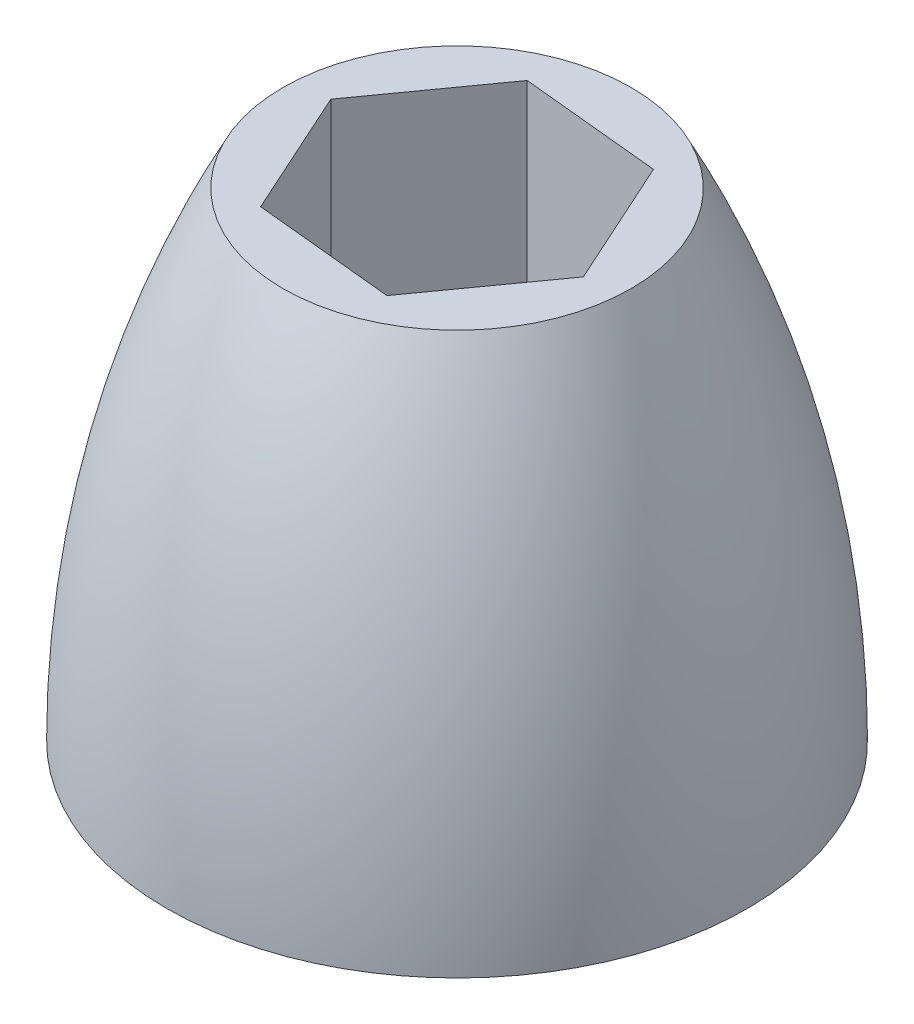
from build123d import *

# Parameters (mm, degrees)
SKETCH1_R               = 19.05
BOSS_EXTRUDE1_DEPTH     = 104.775
CUT_EXTRUDE1_DEPTH      = 104.775
SKETCH5_W               = 79.059329342
SKETCH5_H               = 52.3875
CUT_EXTRUDE2_DEPTH      = 32.7500001
CUT_EXTRUDE2_DEPTH_BACK = 32.7500001


with BuildPart() as part:
    # Sketch1 → Boss-Extrude1 (new body)
    with BuildSketch(Plane(origin=(0, 0, 0), x_dir=(1, 0, 0), z_dir=(0, 1, 0))):
        Circle(SKETCH1_R)
    extrude(amount=BOSS_EXTRUDE1_DEPTH)

    # Sketch2 → Cut-Extrude1 (cut)
    with BuildSketch(Plane.XZ):
        Polygon((-15.323636661, -1.510781079), (-6.353443536, -14.026049167), (8.970193125, -12.515268087), (15.323636661, 1.510781079), (6.353443536, 14.026049167), (-8.970193125, 12.515268087), align=None)
    extrude(amount=-CUT_EXTRUDE1_DEPTH, mode=Mode.SUBTRACT)

    # Sketch4 → Revolve1 (revolve)
    with BuildSketch(Plane.XY):
        with BuildLine():
            Line((-19.05, 104.775), (-19.05, 0))
            ThreePointArc((-19.05, 0), (-31.75, 52.3875), (-19.05, 104.775))
        make_face()
    revolve(axis=Axis((0, 0, 0), (0, 1, 0)))

    # Sketch5 → Cut-Extrude2 (cut, two sides)
    with BuildSketch(Plane.XY) as cut_extrude2_sk:
        with Locations((-0.139680794, 26.19375)):
            Rectangle(SKETCH5_W, SKETCH5_H)
    extrude(amount=CUT_EXTRUDE2_DEPTH, mode=Mode.SUBTRACT)
    extrude(cut_extrude2_sk.sketch, amount=-CUT_EXTRUDE2_DEPTH_BACK, mode=Mode.SUBTRACT)


solid = part.part
